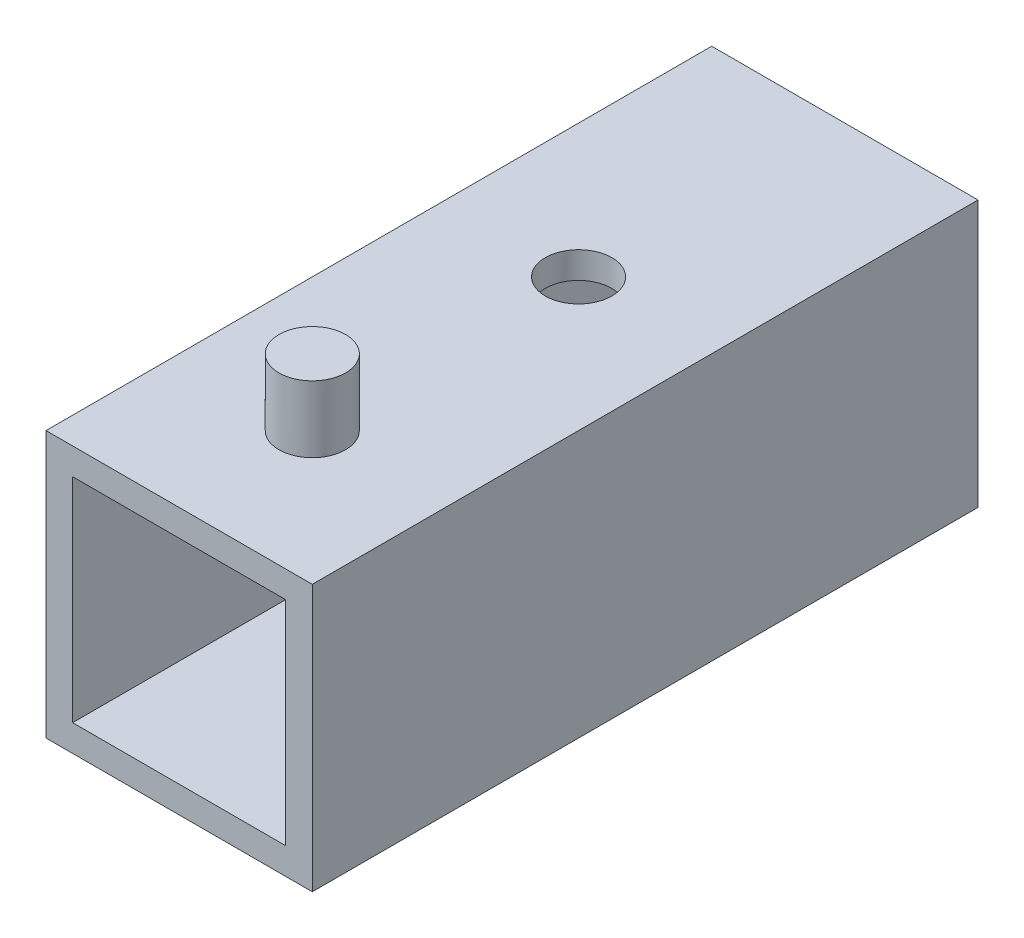
from build123d import *

# Parameters (mm, degrees)
SKETCH1_W           = 25.4
SKETCH1_H           = 25.4
SKETCH1_W_2         = 20.32
SKETCH1_H_2         = 20.32
EXTRUDE_THIN1_DEPTH = 31.75
SKETCH2_R           = 3.175
BOSS_EXTRUDE1_DEPTH = 6.35
SKETCH4_R           = 3.175
CUT_EXTRUDE1_DEPTH  = 26.4


with BuildPart() as part:
    # Sketch1 → Extrude-Thin1 (new body, symmetric)
    with BuildSketch(Plane.XY):
        Rectangle(SKETCH1_W, SKETCH1_H)
        Rectangle(SKETCH1_W_2, SKETCH1_H_2, mode=Mode.SUBTRACT)
    extrude(amount=EXTRUDE_THIN1_DEPTH, both=True)

    # Sketch2 → Boss-Extrude1 (add)
    with BuildSketch(Plane(origin=(0, 12.7, 0), x_dir=(1, 0, 0), z_dir=(0, 1, 0))):
        with Locations((0, -19.05)):
            Circle(SKETCH2_R)
    extrude(amount=BOSS_EXTRUDE1_DEPTH)

    # Sketch4 → Cut-Extrude1 (cut, through all)
    with BuildSketch(Plane(origin=(0, 12.7, 0), x_dir=(1, 0, 0), z_dir=(0, 1, 0))):
        with Locations((0, 6.35)):
            Circle(SKETCH4_R)
    extrude(amount=-CUT_EXTRUDE1_DEPTH, mode=Mode.SUBTRACT)


solid = part.part
